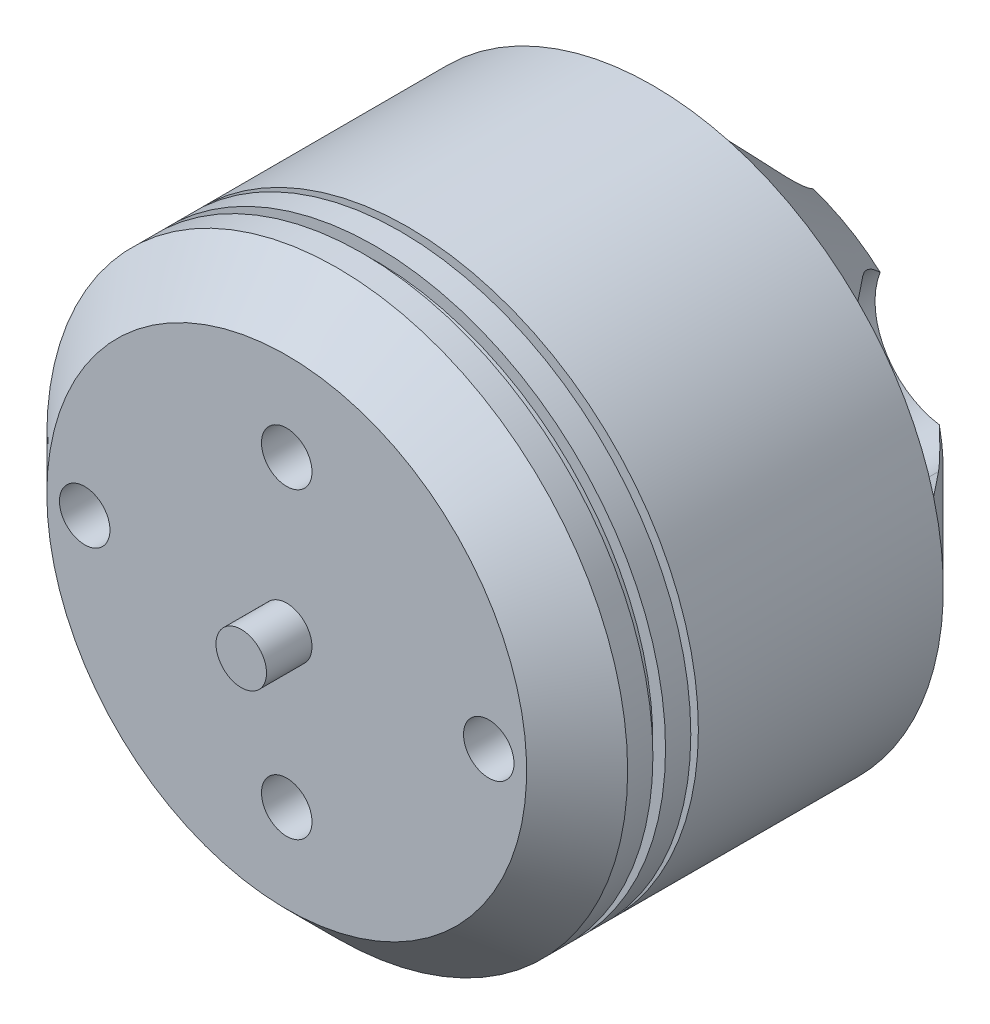
from build123d import *

# Parameters (mm, degrees)
SKETCH3_R          = 1
CUT_EXTRUDE1_DEPTH = 4
SKETCH4_R          = 1
CUT_EXTRUDE2_DEPTH = 3


with BuildPart() as part:
    # Sketch2 → Revolve1 (revolve)
    with BuildSketch(Plane(origin=(0, 0, 0), x_dir=(1, 0, 0), z_dir=(0, 1, 0))):
        Polygon((0, 20.711668775), (0, 0), (0, -3.088331225), (1, -3.088331225), (1, -1.288331225), (9.5, -1.288331225), (11.5, 0.711668775), (11.5, 1.711668775), (11, 1.711668775), (11, 2.211668775), (11.5, 2.211668775), (11.5, 3.211668775), (9.5, 3.211668775), (9.5, 3.511668775), (11.5, 3.511668775), (11.5, 13.211668775), (7.5, 17.211668775), (1, 17.211668775), (1, 20.711668775), align=None)
        Polygon((2.454698557, 16.211668775), (2.454698557, 15.211668775), (1.454698557, 15.211668775), (1.454698557, 11.092814322), (10.5, 11.092814322), (10.5, 12.797455213), (7.085786438, 16.211668775), align=None, mode=Mode.SUBTRACT)
    revolve(axis=Axis((0, 0, -20.711668775), (0, 0, 1)))

    # Sketch3 → Cut-Extrude1 (cut)
    with BuildSketch(Plane(origin=(0, 0, -17.211668775), x_dir=(-1, 0, 0), z_dir=(0, 0, -1))):
        with Locations((0, 4.5)):
            Circle(SKETCH3_R)
        with Locations((4.5, 0)):
            Circle(SKETCH3_R)
        with Locations((0, -4.5)):
            Circle(SKETCH3_R)
        with Locations((-4.5, 0)):
            Circle(SKETCH3_R)
        with BuildLine():
            Line((-3, 9), (-3, 16.651953035))
            Line((-3, 16.651953035), (3, 16.651953035))
            Line((3, 16.651953035), (3, 9))
            ThreePointArc((3, 9), (0, 6), (-3, 9))
        make_face()
        with BuildLine():
            Line((15.921014351, 5.727900306), (9.294228634, 1.901923789))
            ThreePointArc((9.294228634, 1.901923789), (5.196152423, 3), (6.294228634, 7.098076211))
            Line((6.294228634, 7.098076211), (12.921014351, 10.924052729))
            Line((12.921014351, 10.924052729), (15.921014351, 5.727900306))
        make_face()
        with BuildLine():
            Line((12.921014351, -10.924052729), (6.294228634, -7.098076211))
            ThreePointArc((6.294228634, -7.098076211), (5.196152423, -3), (9.294228634, -1.901923789))
            Line((9.294228634, -1.901923789), (15.921014351, -5.727900306))
            Line((15.921014351, -5.727900306), (12.921014351, -10.924052729))
        make_face()
        with BuildLine():
            Line((-3, -16.651953035), (-3, -9))
            ThreePointArc((-3, -9), (0, -6), (3, -9))
            Line((3, -9), (3, -16.651953035))
            Line((3, -16.651953035), (-3, -16.651953035))
        make_face()
        with BuildLine():
            Line((-15.921014351, -5.727900306), (-9.294228634, -1.901923789))
            ThreePointArc((-9.294228634, -1.901923789), (-5.196152423, -3), (-6.294228634, -7.098076211))
            Line((-6.294228634, -7.098076211), (-12.921014351, -10.924052729))
            Line((-12.921014351, -10.924052729), (-15.921014351, -5.727900306))
        make_face()
        with BuildLine():
            Line((-12.921014351, 10.924052729), (-6.294228634, 7.098076211))
            ThreePointArc((-6.294228634, 7.098076211), (-5.196152423, 3), (-9.294228634, 1.901923789))
            Line((-9.294228634, 1.901923789), (-15.921014351, 5.727900306))
            Line((-15.921014351, 5.727900306), (-12.921014351, 10.924052729))
        make_face()
    extrude(amount=-CUT_EXTRUDE1_DEPTH, mode=Mode.SUBTRACT)

    # Sketch4 → Cut-Extrude2 (cut)
    with BuildSketch(Plane.XY.offset(1.288331225)):
        with Locations((0, 6)):
            Circle(SKETCH4_R)
        with Locations((0, -6)):
            Circle(SKETCH4_R)
        with Locations((8, 0)):
            Circle(SKETCH4_R)
        with Locations((-8, 0)):
            Circle(SKETCH4_R)
    extrude(amount=-CUT_EXTRUDE2_DEPTH, mode=Mode.SUBTRACT)


solid = part.part
